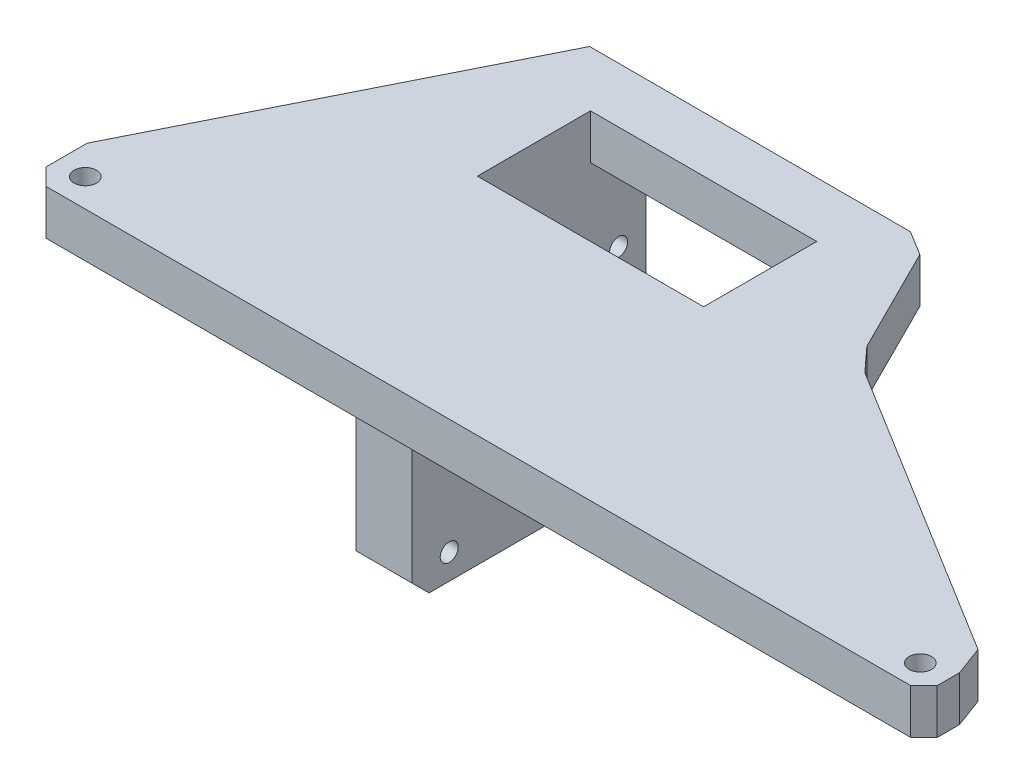
from build123d import *

# Parameters (mm, degrees)
CROQUIS1_R              = 2
CROQUIS1_W              = 53.3
CROQUIS1_H              = 20.15
SALIENTE_EXTRUIR1_DEPTH = 8
CROQUIS2_W              = 10
CROQUIS2_H              = 41.6
SALIENTE_EXTRUIR2_DEPTH = 60
CROQUIS2_4_W            = 5
CROQUIS2_4_H            = 20.15
SALIENTE_EXTRUIR3_DEPTH = 18
CROQUIS3_R              = 2
CORTAR_EXTRUIR1_DEPTH   = 107
CROQUIS3_3_R            = 2
CORTAR_EXTRUIR2_DEPTH   = 8
CROQUIS5_R              = 1.6
CROQUIS5_R_2            = 12
CORTAR_EXTRUIR3_DEPTH   = 59


with BuildPart() as part:
    # Croquis1 → Saliente-Extruir1 (new body)
    with BuildSketch(Plane(origin=(0, 0, 0), x_dir=(1, 0, 0), z_dir=(0, 1, 0))):
        Polygon((154, 0), (156.396068252, 2.352828169), (156.396068252, 6.352828169), (154.446539538, 11.574918968), (101.665094886, 44.198861104), (97.772883017, 48.458390041), (88.347282669, 67.313746258), (84.009081739, 69.99516616), (26.841381739, 69.99516616), (-2.995601596, 10.334082852), (-2.995601596, 3.004082852), (0, 0), align=None)
        with Locations((2, 5)):
            Circle(CROQUIS1_R, mode=Mode.SUBTRACT)
        with Locations((151.397935499, 4.352828169)):
            Circle(CROQUIS1_R, mode=Mode.SUBTRACT)
        with Locations((55.5, 50.075)):
            Rectangle(CROQUIS1_W, CROQUIS1_H, mode=Mode.SUBTRACT)
    extrude(amount=SALIENTE_EXTRUIR1_DEPTH)

    # Croquis2 → Saliente-Extruir2 (add)
    with BuildSketch(Plane(origin=(0, 8, 0), x_dir=(1, 0, 0), z_dir=(0, 1, 0))):
        with Locations((31.841381739, 49.19516616)):
            Rectangle(CROQUIS2_W, CROQUIS2_H)
    extrude(amount=-SALIENTE_EXTRUIR2_DEPTH)

    # Croquis2_4 → Saliente-Extruir3 (add)
    with BuildSketch(Plane(origin=(0, 8, 0), x_dir=(1, 0, 0), z_dir=(0, 1, 0))):
        with Locations((79.65, 50.075)):
            Rectangle(CROQUIS2_4_W, CROQUIS2_4_H)
    extrude(amount=-SALIENTE_EXTRUIR3_DEPTH)

    # Croquis3 → Cortar-Extruir1 (cut)
    with BuildSketch(Plane(origin=(82.15, 0, 0), x_dir=(0, 0, -1), z_dir=(1, 0, 0))):
        with Locations((50.075, -5)):
            Circle(CROQUIS3_R)
    extrude(amount=-CORTAR_EXTRUIR1_DEPTH, mode=Mode.SUBTRACT)

    # Croquis3_3 → Cortar-Extruir2 (cut)
    with BuildSketch(Plane(origin=(82.15, 0, 0), x_dir=(0, 0, -1), z_dir=(1, 0, 0))):
        with Locations((50.075, -5)):
            Circle(CROQUIS3_3_R)
        with BuildLine():
            Line((59.15, -10), (60.15, -10))
            Line((60.15, -10), (60.15, -9))
            ThreePointArc((60.15, -9), (59.857106781, -9.707106781), (59.15, -10))
        make_face()
        with BuildLine():
            Line((40, -10), (40, -9))
            ThreePointArc((40, -9), (40.292893219, -9.707106781), (41, -10))
            Line((41, -10), (40, -10))
        make_face()
    extrude(amount=-CORTAR_EXTRUIR2_DEPTH, mode=Mode.SUBTRACT)

    # Croquis5 → Cortar-Extruir3 (cut)
    with BuildSketch(Plane(origin=(36.841381739, 0, 0), x_dir=(0, 0, -1), z_dir=(1, 0, 0))):
        with Locations((65.165, -15.5)):
            Circle(CROQUIS5_R)
        with Locations((50.075, -31.5)):
            Circle(CROQUIS5_R_2)
        with Locations((65.165, -47.5)):
            Circle(CROQUIS5_R)
        with Locations((34.985, -15.5)):
            Circle(CROQUIS5_R)
        with Locations((34.985, -47.5)):
            Circle(CROQUIS5_R)
        Polygon((28.39516616, -52), (28.39516616, -49), (31.39516616, -52), align=None)
        Polygon((69.99516616, -52), (69.99516616, -49), (66.99516616, -52), align=None)
    extrude(amount=-CORTAR_EXTRUIR3_DEPTH, mode=Mode.SUBTRACT)


solid = part.part
